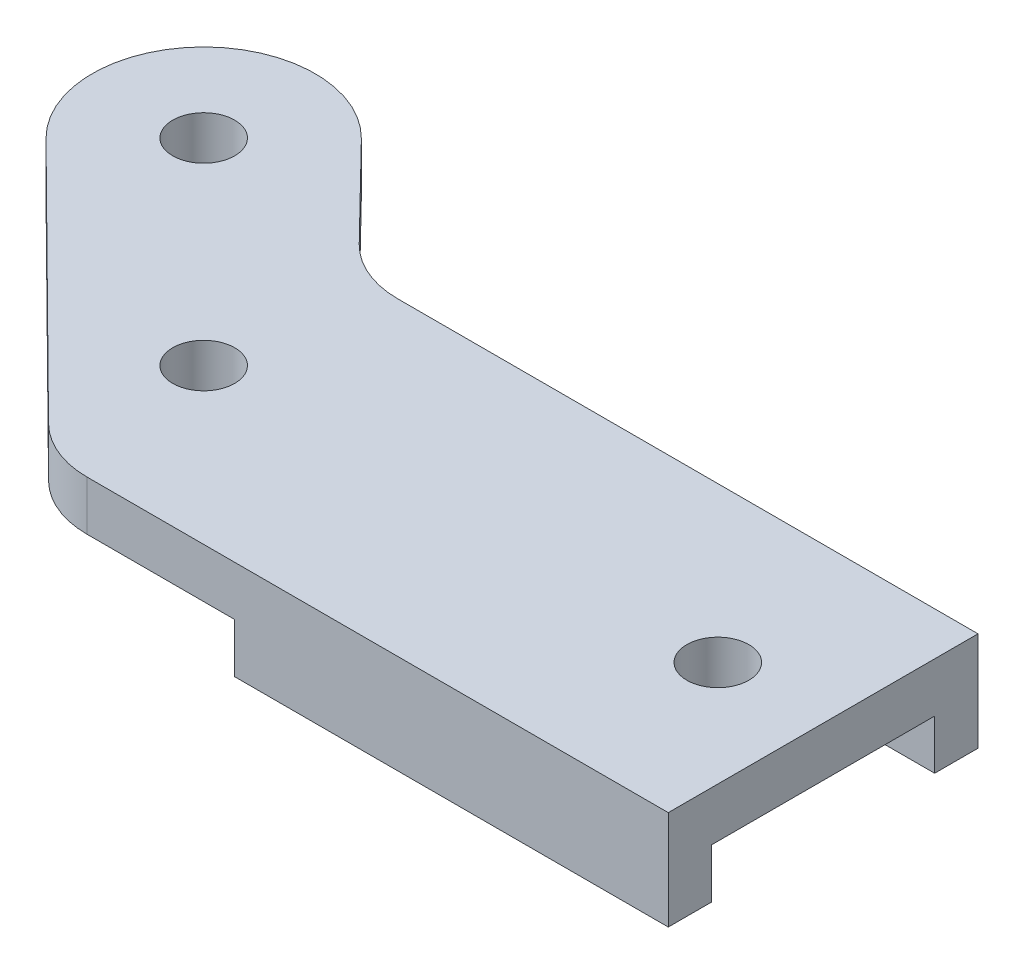
from build123d import *

# Parameters (mm, degrees)
SKETCH1_R           = 5
BOSS_EXTRUDE1_DEPTH = 8
BOSS_EXTRUDE2_DEPTH = 8
FILLET1_R           = 15


with BuildPart() as part:
    # Sketch1 → Boss-Extrude1 (new body)
    with BuildSketch(Plane(origin=(0, 0, 0), x_dir=(1, 0, 0), z_dir=(0, 1, 0))):
        with BuildLine():
            Line((0, -25), (100, -25))
            Line((100, -25), (100, 25))
            Line((100, 25), (0, 25))
            Line((0, 25), (-18.942042706, 44.396101681))
            ThreePointArc((-18.942042706, 44.396101681), (-44.505039362, 44.590272375), (-44.48205564, 19.026548624))
            Line((-44.48205564, 19.026548624), (0, -25))
        make_face()
        with Locations((-31.819805153, 31.819805153)):
            Circle(SKETCH1_R, mode=Mode.SUBTRACT)
        Circle(SKETCH1_R, mode=Mode.SUBTRACT)
        with Locations((83, 0)):
            Circle(SKETCH1_R, mode=Mode.SUBTRACT)
    extrude(amount=BOSS_EXTRUDE1_DEPTH)

    # Sketch2 → Boss-Extrude2 (add)
    with BuildSketch(Plane.XZ):
        Polygon((100, 25), (30, 25), (30, -25), (100, -25), (100, -18), (50, -18), (50, 18), (100, 18), align=None)
    extrude(amount=BOSS_EXTRUDE2_DEPTH)

    # Fillet1
    fillet1_edges = [part.edges().sort_by_distance(p)[0] for p in [
        (0, 4, -25),
        (0, 4, 25),
    ]]
    fillet(fillet1_edges, radius=FILLET1_R)


solid = part.part
